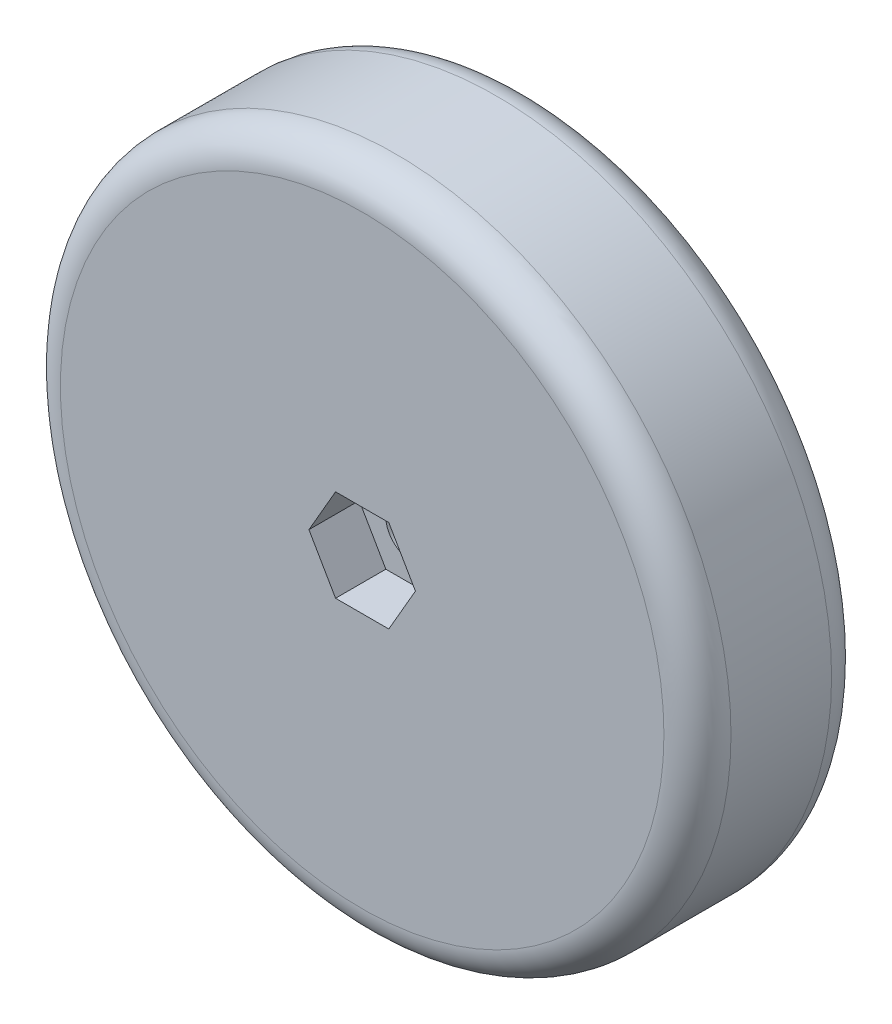
from build123d import *

# Parameters (mm, degrees)
SCHIZZO1_R                   = 20
SCHIZZO1_R_2                 = 1.6
ESTRUSIONE_ESTRUSIONE1_DEPTH = 10
TAGLIO_ESTRUSIONE1_DEPTH     = 3
RACCORDO1_R                  = 2
SCHIZZO3_R                   = 5
SCHIZZO3_R_2                 = 1.6
ESTRUSIONE_ESTRUSIONE2_DEPTH = 0.5


with BuildPart() as part:
    # Schizzo1 → Estrusione-Estrusione1 (new body)
    with BuildSketch(Plane.XY):
        Circle(SCHIZZO1_R)
        Circle(SCHIZZO1_R_2, mode=Mode.SUBTRACT)
    extrude(amount=ESTRUSIONE_ESTRUSIONE1_DEPTH)

    # Schizzo2 → Taglio-Estrusione1 (cut)
    with BuildSketch(Plane.XY.offset(10)):
        Polygon((3.175426481, 0), (1.58771324, 2.75), (-1.58771324, 2.75), (-3.175426481, 0), (-1.58771324, -2.75), (1.58771324, -2.75), align=None)
    extrude(amount=-TAGLIO_ESTRUSIONE1_DEPTH, mode=Mode.SUBTRACT)

    # Raccordo1
    raccordo1_edges = [part.edges().sort_by_distance(p)[0] for p in [
        (-20, 0, 0),
        (-20, 0, 10),
    ]]
    fillet(raccordo1_edges, radius=RACCORDO1_R)

    # Schizzo3 → Estrusione-Estrusione2 (add)
    with BuildSketch(Plane(origin=(0, 0, 0), x_dir=(-1, 0, 0), z_dir=(0, 0, -1))):
        Circle(SCHIZZO3_R)
        Circle(SCHIZZO3_R_2, mode=Mode.SUBTRACT)
    extrude(amount=ESTRUSIONE_ESTRUSIONE2_DEPTH)


solid = part.part
